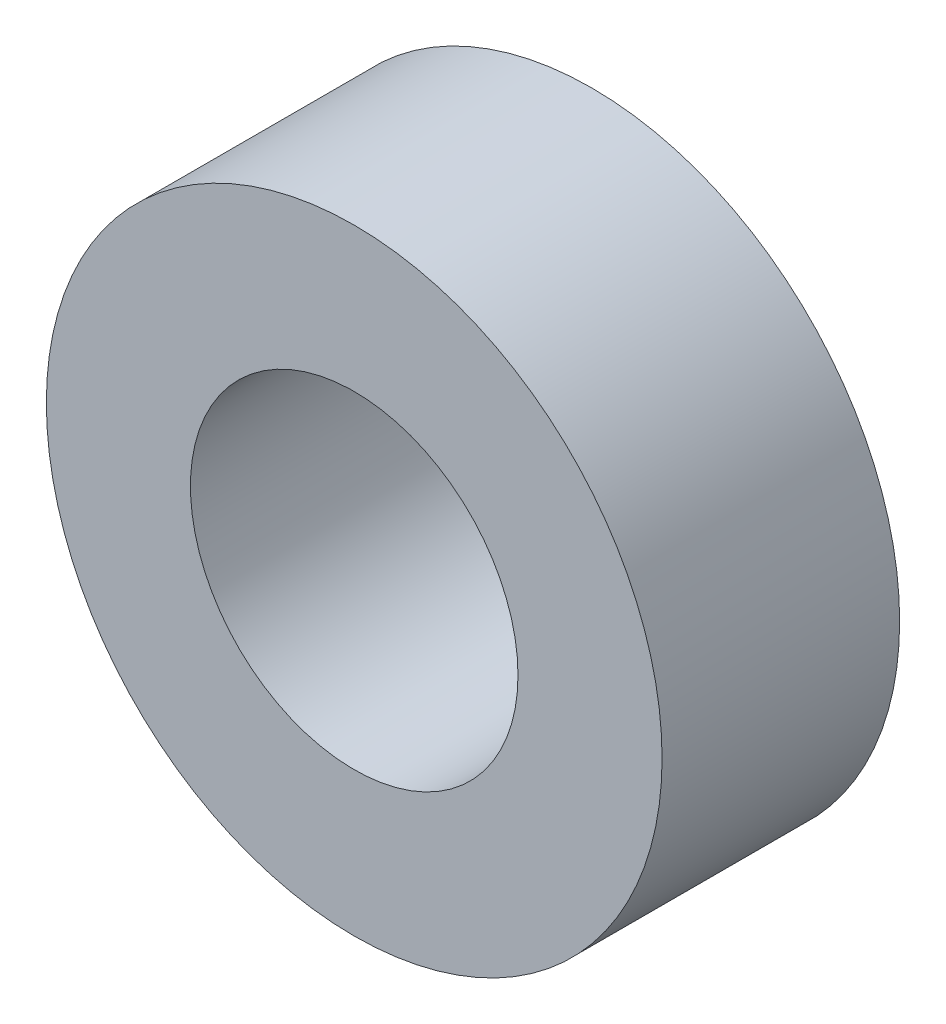
from build123d import *

# Parameters (mm, degrees)
SKETCH1_R           = 6.35
SKETCH1_R_2         = 3.3782
BOSS_EXTRUDE1_DEPTH = 4.9


with BuildPart() as part:
    # Sketch1 → Boss-Extrude1 (new body)
    with BuildSketch(Plane.XY):
        Circle(SKETCH1_R)
        Circle(SKETCH1_R_2, mode=Mode.SUBTRACT)
    extrude(amount=BOSS_EXTRUDE1_DEPTH)


solid = part.part
